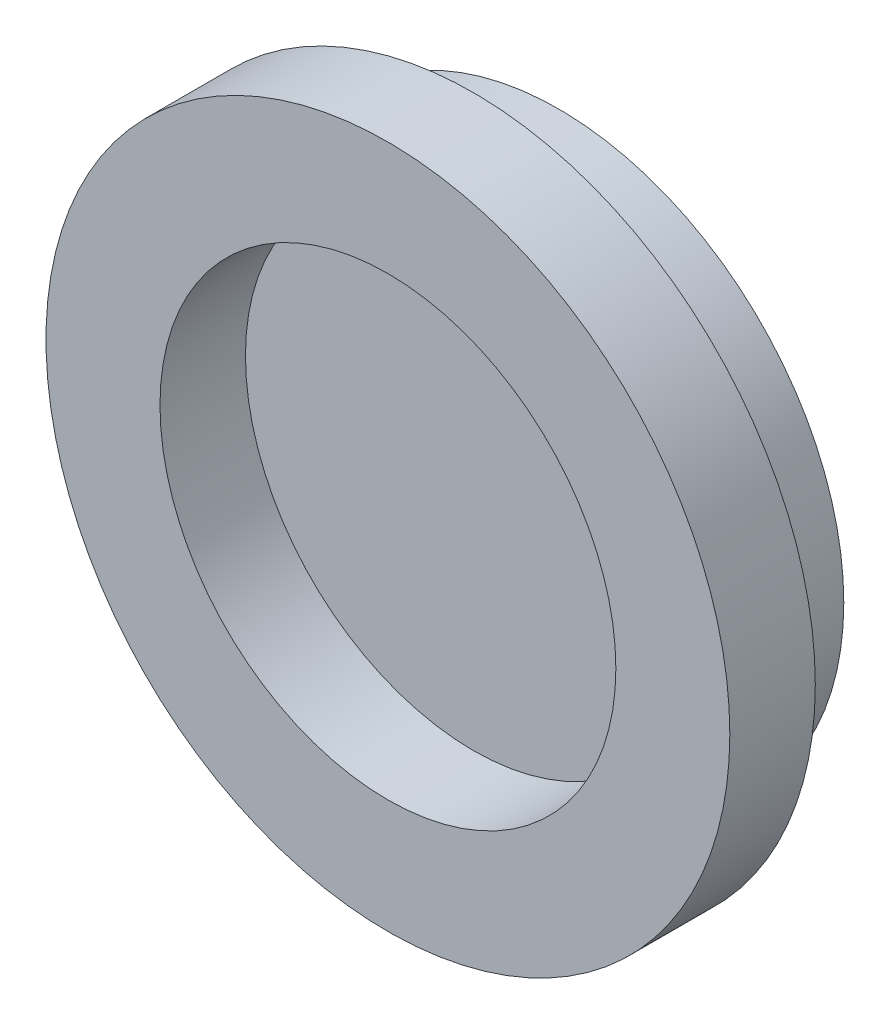
from build123d import *

# Parameters (mm, degrees)
SKETCH1_R           = 10
BOSS_EXTRUDE1_DEPTH = 3
SKETCH2_R           = 12
SKETCH2_R_2         = 8
BOSS_EXTRUDE2_DEPTH = 3


with BuildPart() as part:
    # Sketch1 → Boss-Extrude1 (new body)
    with BuildSketch(Plane.XY):
        Circle(SKETCH1_R)
    extrude(amount=BOSS_EXTRUDE1_DEPTH)

    # Sketch2 → Boss-Extrude2 (add)
    with BuildSketch(Plane.XY.offset(3)):
        Circle(SKETCH2_R)
        Circle(SKETCH2_R_2, mode=Mode.SUBTRACT)
    extrude(amount=BOSS_EXTRUDE2_DEPTH)


solid = part.part
